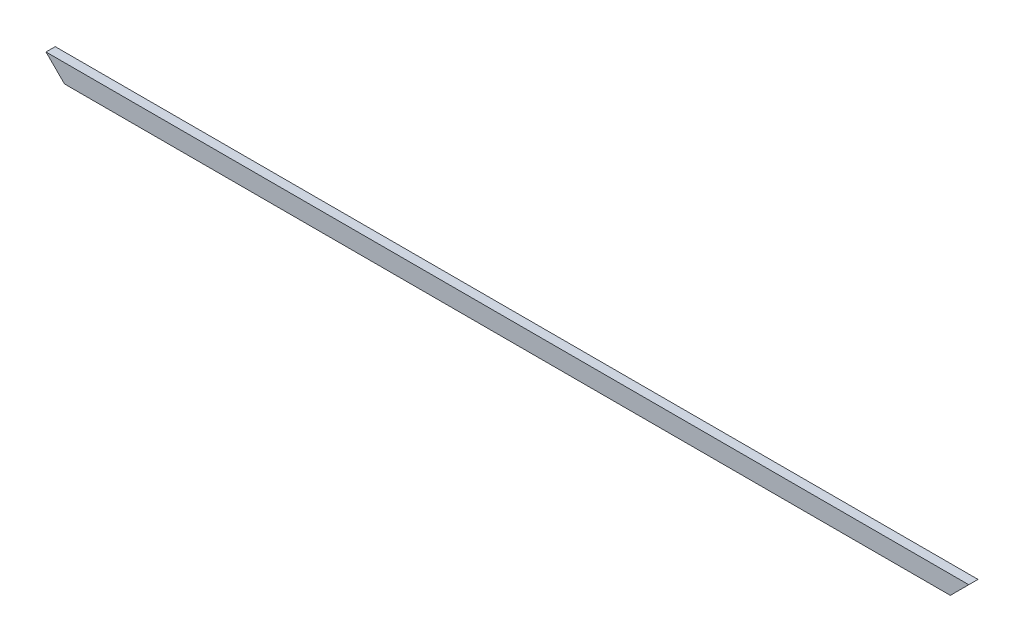
from build123d import *

# Parameters (mm, degrees)
BOSS_EXTRU_1_DEPTH = 10


with BuildPart() as part:
    # Esquisse1 → Boss.-Extru.1 (new body)
    with BuildSketch(Plane.XY):
        Polygon((0, 0), (-960, 0), (-980, 20), (20, 20), align=None)
    extrude(amount=BOSS_EXTRU_1_DEPTH)


solid = part.part
